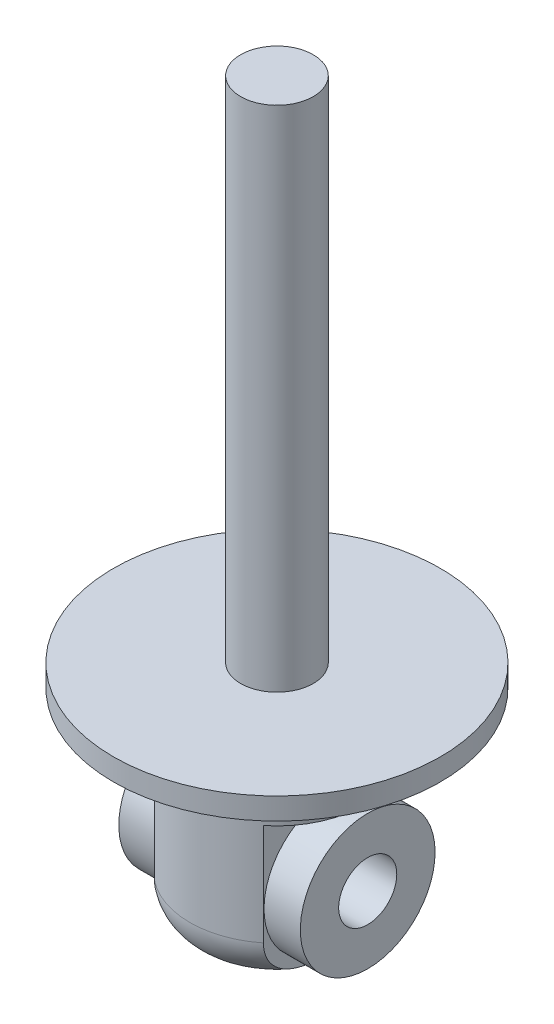
from build123d import *

# Parameters (mm, degrees)
SKETCH1_R               = 22.5
BOSS_EXTRUDE3_DEPTH     = 3
SKETCH3_R               = 5
BOSS_EXTRUDE4_DEPTH     = 70
SKETCH4_R               = 12
BOSS_EXTRUDE5_DEPTH     = 28
FILLET1_R               = 6
SKETCH6_W               = 20
SKETCH6_H               = 20
CUT_EXTRUDE1_DEPTH      = 23.5
CUT_EXTRUDE1_DEPTH_BACK = 23.5
SKETCH7_R               = 4
CUT_EXTRUDE2_DEPTH      = 28
SKETCH10_R              = 9.27822292
SKETCH10_R_2            = 4
BOSS_EXTRUDE6_DEPTH     = 12.5


with BuildPart() as part:
    # Sketch1 → Boss-Extrude3 (new body)
    with BuildSketch(Plane(origin=(0, 0, 0), x_dir=(1, 0, 0), z_dir=(0, 1, 0))):
        Circle(SKETCH1_R)
    extrude(amount=BOSS_EXTRUDE3_DEPTH)

    # Sketch3 → Boss-Extrude4 (add)
    with BuildSketch(Plane(origin=(0, 3, 0), x_dir=(1, 0, 0), z_dir=(0, 1, 0))):
        Circle(SKETCH3_R)
    extrude(amount=BOSS_EXTRUDE4_DEPTH)

    # Sketch4 → Boss-Extrude5 (add)
    with BuildSketch(Plane.XZ):
        Circle(SKETCH4_R)
    extrude(amount=BOSS_EXTRUDE5_DEPTH)

    # Fillet1
    fillet1_edges = [part.edges().sort_by_distance(p)[0] for p in [
        (-12, -28, 0),
    ]]
    fillet(fillet1_edges, radius=FILLET1_R)

    # Sketch6 → Cut-Extrude1 (cut, two sides)
    with BuildSketch(Plane.XY) as cut_extrude1_sk:
        with Locations((17.5, -18)):
            Rectangle(SKETCH6_W, SKETCH6_H)
        with Locations((-17.5, -18)):
            Rectangle(SKETCH6_W, SKETCH6_H)
    extrude(amount=CUT_EXTRUDE1_DEPTH, mode=Mode.SUBTRACT)
    extrude(cut_extrude1_sk.sketch, amount=-CUT_EXTRUDE1_DEPTH_BACK, mode=Mode.SUBTRACT)

    # Sketch7 → Cut-Extrude2 (cut)
    with BuildSketch(Plane(origin=(7.5, 0, 0), x_dir=(0, 0, -1), z_dir=(1, 0, 0))):
        with Locations((0, -18)):
            Circle(SKETCH7_R)
    extrude(amount=-CUT_EXTRUDE2_DEPTH, mode=Mode.SUBTRACT)

    # Sketch10 → Boss-Extrude6 (add, symmetric)
    with BuildSketch(Plane(origin=(0, 0, 0), x_dir=(0, 0, -1), z_dir=(1, 0, 0))):
        with Locations((0, -18)):
            Circle(SKETCH10_R)
        with Locations((0, -18)):
            Circle(SKETCH10_R_2, mode=Mode.SUBTRACT)
    extrude(amount=BOSS_EXTRUDE6_DEPTH, both=True)


solid = part.part
